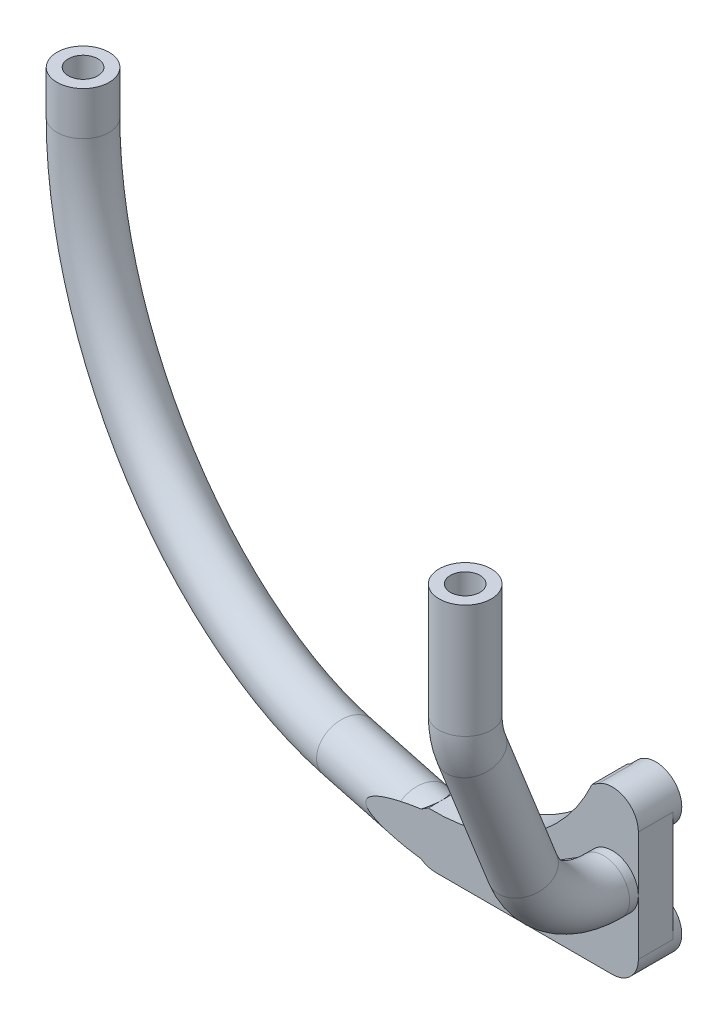
from build123d import *

# Parameters (mm, degrees)
SKIZZE1_R                         = 3
AUFSATZ_LINEAR_AUSTRAGEN1_DEPTH   = 5
AUFSATZ_LINEAR_AUSTRAGEN1_2_DEPTH = 5
AUFSATZ_LINEAR_AUSTRAGEN1_3_DEPTH = 5
SKIZZE3_R                         = 3
SKIZZE6_W                         = 20.32
SKIZZE6_H                         = 6
AUFSATZ_LINEAR_AUSTRAGEN2_DEPTH   = 4
AUFSATZ_LINEAR_START              = -5
SKIZZE8_W                         = 6
SKIZZE8_H                         = 12.7
AUFSATZ_LINEAR_AUSTRAGEN3_DEPTH   = 4
AUFSATZ_LINEAR_AUSTRAGEN4_DEPTH   = 4
SKIZZE14_R                        = 3
SCHNITT_LINEAR_AUSTRAGEN2_DEPTH   = 48.39873951
SKIZZE16_R                        = 1.7
SCHNITT_LINEAR_AUSTRAGEN3_DEPTH   = 4
SKIZZE17_R                        = 1.7
SCHNITT_LINEAR_AUSTRAGEN4_DEPTH   = 4
SCHNITT_LINEAR_AUSTRAGEN6_DEPTH   = 4


with BuildPart() as part:
    # Skizze1 → Aufsatz-Linear austragen1 (new body)
    with BuildSketch(Plane.XY):
        with Locations((-2.54, 15.24)):
            Circle(SKIZZE1_R)
    extrude(amount=AUFSATZ_LINEAR_AUSTRAGEN1_DEPTH)



with BuildPart() as body_2:
    # Skizze1 → Aufsatz-Linear austragen1 2 (new body)
    with BuildSketch(Plane.XY):
        with Locations((-2.54, 2.54)):
            Circle(SKIZZE1_R)
    extrude(amount=AUFSATZ_LINEAR_AUSTRAGEN1_2_DEPTH)



with BuildPart() as body_3:
    # Skizze1 → Aufsatz-Linear austragen1 3 (new body)
    with BuildSketch(Plane.XY):
        with Locations((-22.86, 2.54)):
            Circle(SKIZZE1_R)
    extrude(amount=AUFSATZ_LINEAR_AUSTRAGEN1_3_DEPTH)


with BuildPart() as body_4:
    # Austragung1: sweep along a path in Skizze2
    with BuildLine(Plane(origin=(0, 0, 0), x_dir=(0, 0, -1), z_dir=(1, 0, 0))) as austragung1_path:
        Line((-21.93, 46.93873951), (-21.93, 33.848580958))
        ThreePointArc((-21.93, 33.848580958), (-21.752467402, 31.972645421), (-21.226173172, 30.163317826))
        Line((-21.226173172, 30.163317826), (-15.296173172, 15.204736868))
        ThreePointArc((-15.296173172, 15.204736868), (-11.619046569, 10.617979953), (-6, 8.89))
        Line((-6, 8.89), (-5, 8.89))
    # Skizze3 → Austragung1 (sweep)
    with BuildSketch(Plane.XY.offset(5)):
        with Locations((-2.54, 8.89)):
            Circle(SKIZZE3_R)
    sweep(path=austragung1_path.line)


with BuildPart() as body_2_1:
    add(body_2.part)

    add(body_3.part)  # Aufsatz-Linear austragen2 merges body 3
    # Skizze6 → Aufsatz-Linear austragen2 (add)
    with BuildSketch(Plane.XY.offset(5)):
        with Locations((-12.7, 2.54)):
            Rectangle(SKIZZE6_W, SKIZZE6_H)
    extrude(amount=-AUFSATZ_LINEAR_AUSTRAGEN2_DEPTH)


with BuildPart() as part_1:
    add(part.part)

    add(body_2_1.part)  # Aufsatz-Linear austragen3 merges body 2

    add(body_4.part)  # Aufsatz-Linear austragen3 merges body 4
    # Skizze8 → Aufsatz-Linear austragen3 (add)
    with BuildSketch(Plane(origin=(0, 0, 0), x_dir=(-1, 0, 0), z_dir=(0, 0, -1)).offset(AUFSATZ_LINEAR_START)):
        with Locations((2.54, 8.89)):
            Rectangle(SKIZZE8_W, SKIZZE8_H)
    extrude(amount=AUFSATZ_LINEAR_AUSTRAGEN3_DEPTH)

    # Skizze9 → Aufsatz-Linear austragen4 (add)
    with BuildSketch(Plane(origin=(0, 0, 0), x_dir=(-1, 0, 0), z_dir=(0, 0, -1)).offset(AUFSATZ_LINEAR_START)):
        Polygon((4.12999682, 17.783994912), (0.95000318, 12.696005088), (21.27000318, -0.003994912), (24.44999682, 5.083994912), align=None)
    extrude(amount=AUFSATZ_LINEAR_AUSTRAGEN4_DEPTH)

    # Austragung3: sweep along a path in Skizze12
    with BuildLine(Plane(origin=(-70.149644345, 31.847131815, -6.332474017), x_dir=(0.978512631, 0, 0.206186883), z_dir=(0.206186883, 0, -0.978512631))) as austragung3_path:
        Line((-6.001962715, -15.091607694), (-6.001962715, -10.091607694))
        ThreePointArc((-6.001962715, -10.091607694), (5.537660917, 17.767508183), (33.396776795, 29.307131815))
        Line((33.396776795, 29.307131815), (44.6436495, 29.307131815))
        Line((44.6436495, 29.307131815), (59.6436495, 29.307131815))
    # Skizze14 → Austragung3 (sweep)
    with BuildSketch(Plane(origin=(0, 46.93873951, 0), x_dir=(-1, 0, 0), z_dir=(0, -1, 0))):
        with Locations((76.022640673, 7.57)):
            Circle(SKIZZE14_R)
    sweep(path=austragung3_path.line)

    # Skizze15 → Schnitt-Linear austragen2 (cut, through all)
    with BuildSketch(Plane(origin=(0, -0.46, 0), x_dir=(-1, 0, 0), z_dir=(0, -1, 0))):
        Polygon((11.584184705, -5), (12.406140588, -8.900802043), (30.918395198, -5), align=None)
    extrude(amount=-SCHNITT_LINEAR_AUSTRAGEN2_DEPTH, mode=Mode.SUBTRACT)

    # Skizze16 → Schnitt-Linear austragen3 (cut)
    with BuildSketch(Plane(origin=(0, 46.93873951, 0), x_dir=(1, 0, 0), z_dir=(0, 1, 0))):
        with Locations((-2.54, -21.93)):
            Circle(SKIZZE16_R)
        with Locations((-76.022640673, 7.57)):
            Circle(SKIZZE16_R)
    extrude(amount=-SCHNITT_LINEAR_AUSTRAGEN3_DEPTH, mode=Mode.SUBTRACT)

    # Skizze17 → Schnitt-Linear austragen4 (cut)
    with BuildSketch(Plane(origin=(0, 0, 0), x_dir=(-1, 0, 0), z_dir=(0, 0, -1))):
        with Locations((2.54, 2.54)):
            Circle(SKIZZE17_R)
        with Locations((2.54, 15.24)):
            Circle(SKIZZE17_R)
        with Locations((22.86, 2.54)):
            Circle(SKIZZE17_R)
    extrude(amount=-SCHNITT_LINEAR_AUSTRAGEN4_DEPTH, mode=Mode.SUBTRACT)

    # Skizze19 → Schnitt-Linear austragen6 (cut)
    with BuildSketch(Plane(origin=(0, 0, 1), x_dir=(-1, 0, 0), z_dir=(0, 0, -1))):
        with BuildLine():
            Line((4.872034586, 17.320221308), (23.707959054, 5.547768516))
            ThreePointArc((23.707959054, 5.547768516), (12.505452744, 8.57872439), (4.872034586, 17.320221308))
        make_face()
    extrude(amount=-SCHNITT_LINEAR_AUSTRAGEN6_DEPTH, mode=Mode.SUBTRACT)


solid = part_1.part
